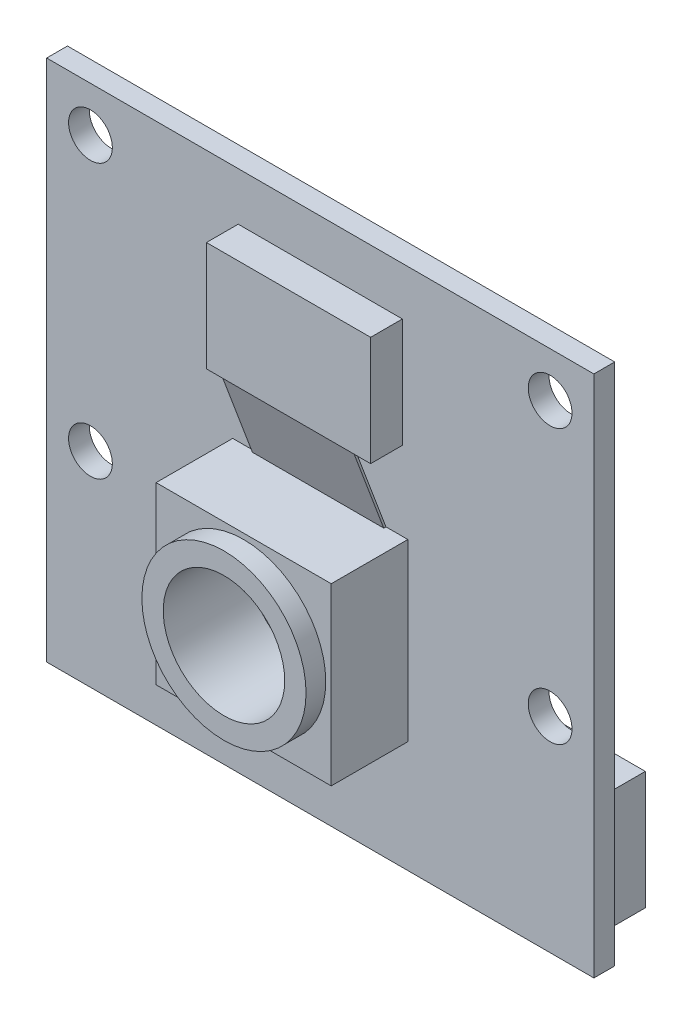
from build123d import *

# Parameters (mm, degrees)
SKETCH1_W           = 25
SKETCH1_H           = 23.9
SKETCH1_R           = 1
BOSS_EXTRUDE1_DEPTH = 0.95
SKETCH2_W           = 7.5
SKETCH2_H           = 5
BOSS_EXTRUDE2_DEPTH = 1.45
SKETCH3_W           = 8
SKETCH3_H           = 8
BOSS_EXTRUDE3_DEPTH = 4.4
SKETCH4_W           = 8
SKETCH4_H           = 8
SKETCH4_R           = 3.75
CUT_EXTRUDE1_DEPTH  = 0.9
SKETCH5_R           = 2.775
CUT_EXTRUDE2_DEPTH  = 3.9
BOSS_EXTRUDE4_DEPTH = 6
BOSS_EXTRUDE5_DEPTH = 2.8


with BuildPart() as part:
    # Sketch1 → Boss-Extrude1 (new body)
    with BuildSketch(Plane.XY):
        with Locations((12.5, 11.95)):
            Rectangle(SKETCH1_W, SKETCH1_H)
        with Locations((23, 9.35)):
            Circle(SKETCH1_R, mode=Mode.SUBTRACT)
        with Locations((2, 9.35)):
            Circle(SKETCH1_R, mode=Mode.SUBTRACT)
        with Locations((23, 21.85)):
            Circle(SKETCH1_R, mode=Mode.SUBTRACT)
        with Locations((2, 21.85)):
            Circle(SKETCH1_R, mode=Mode.SUBTRACT)
    extrude(amount=BOSS_EXTRUDE1_DEPTH)

    # Sketch2 → Boss-Extrude2 (add)
    with BuildSketch(Plane.XY.offset(0.95)):
        with Locations((12.5, 19.2)):
            Rectangle(SKETCH2_W, SKETCH2_H)
    extrude(amount=BOSS_EXTRUDE2_DEPTH)

    # Sketch3 → Boss-Extrude3 (add)
    with BuildSketch(Plane.XY.offset(0.95)):
        with Locations((12.5, 9.1)):
            Rectangle(SKETCH3_W, SKETCH3_H)
    extrude(amount=BOSS_EXTRUDE3_DEPTH)

    # Sketch4 → Cut-Extrude1 (cut)
    with BuildSketch(Plane.XY.offset(5.35)):
        with Locations((12.5, 9.1)):
            Rectangle(SKETCH4_W, SKETCH4_H)
        with Locations((12.5, 9.1)):
            Circle(SKETCH4_R, mode=Mode.SUBTRACT)
    extrude(amount=-CUT_EXTRUDE1_DEPTH, mode=Mode.SUBTRACT)

    # Sketch5 → Cut-Extrude2 (cut)
    with BuildSketch(Plane.XY.offset(5.35)):
        with Locations((12.5, 9.1)):
            Circle(SKETCH5_R)
    extrude(amount=-CUT_EXTRUDE2_DEPTH, mode=Mode.SUBTRACT)

    # Sketch12 → Boss-Extrude4 (add)
    with BuildSketch(Plane(origin=(15.5, 0, 0), x_dir=(0, 0, -1), z_dir=(1, 0, 0))):
        Polygon((-2.4, 16.7), (-2.3, 16.7), (-0.95, 13.1), (-1.05, 13.1), align=None)
    extrude(amount=-BOSS_EXTRUDE4_DEPTH)

    # Sketch13 → Boss-Extrude5 (add)
    with BuildSketch(Plane(origin=(0, 0, 0), x_dir=(-1, 0, 0), z_dir=(0, 0, -1))):
        Polygon((-1.4, 5.6), (-12.5, 5.6), (-23.6, 5.6), (-23.6, 0.2), (-1.4, 0.2), align=None)
    extrude(amount=BOSS_EXTRUDE5_DEPTH)


solid = part.part
